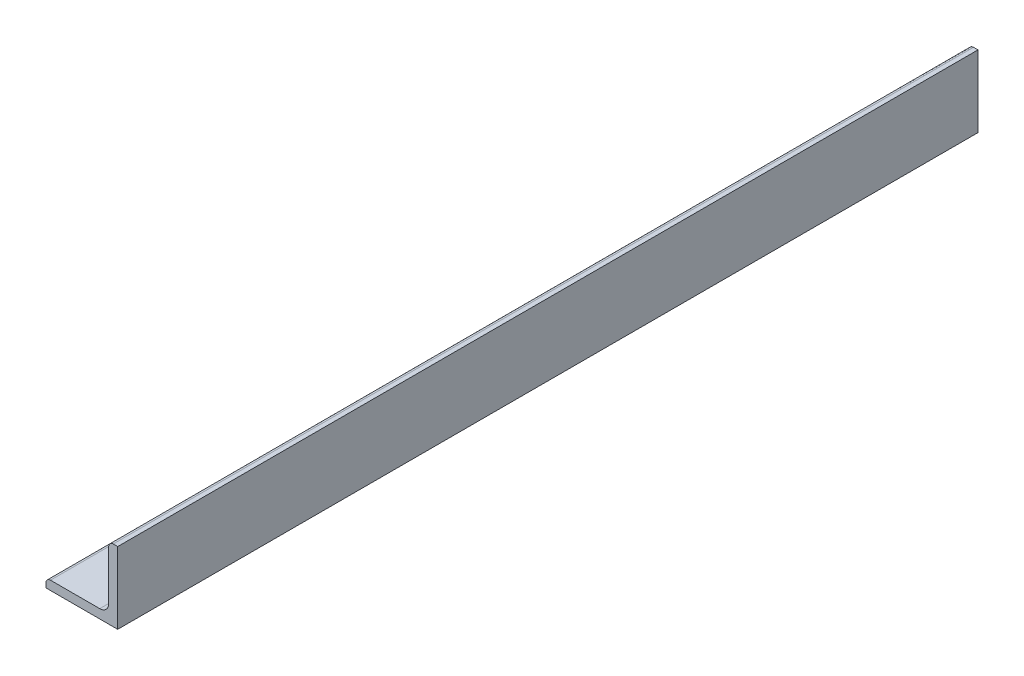
from build123d import *

# Parameters (mm, degrees)
BOSS_EXTRUDE1_DEPTH = 152.4


with BuildPart() as part:
    # Sketch2 → Boss-Extrude1 (new, symmetric)
    with BuildSketch(Plane.XY):
        with BuildLine():
            Line((-12.7, -12.7), (12.7, -12.7))
            Line((12.7, -12.7), (12.7, 12.7))
            Line((12.7, 12.7), (11.1125, 12.7))
            ThreePointArc((11.1125, 12.7), (9.989967985, 12.235032015), (9.525, 11.1125))
            Line((9.525, 11.1125), (9.525, -6.35))
            ThreePointArc((9.525, -6.35), (8.59506403, -8.59506403), (6.35, -9.525))
            Line((6.35, -9.525), (-11.1125, -9.525))
            ThreePointArc((-11.1125, -9.525), (-12.235032015, -9.989967985), (-12.7, -11.1125))
            Line((-12.7, -11.1125), (-12.7, -12.7))
        make_face()
    extrude(amount=BOSS_EXTRUDE1_DEPTH, both=True)


solid = part.part
